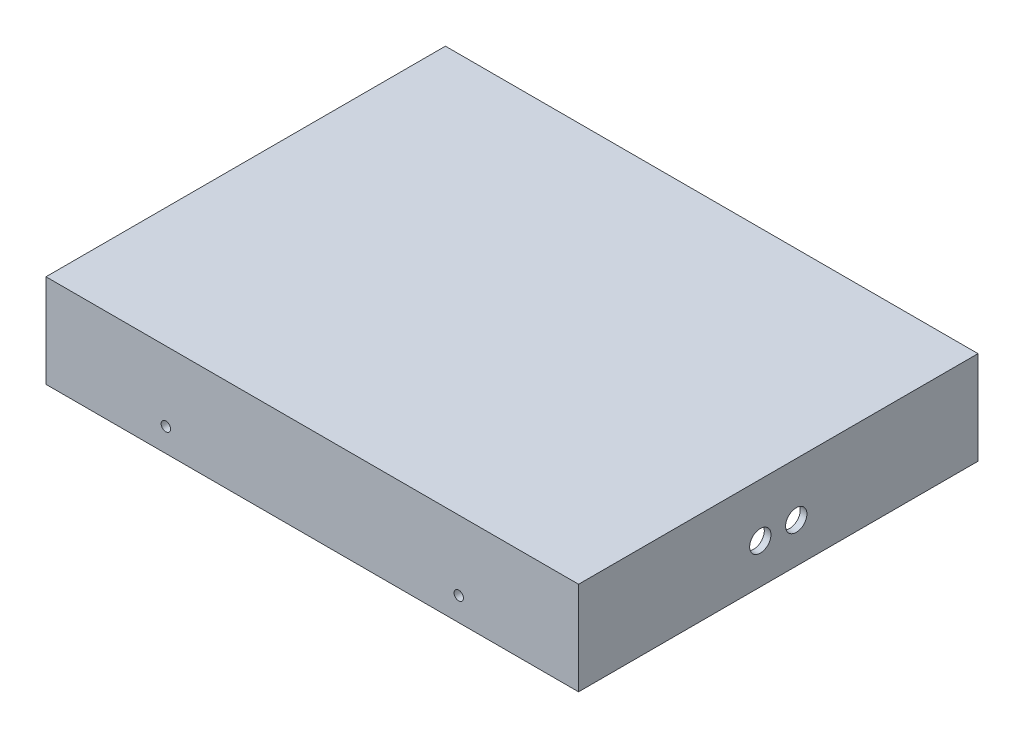
from build123d import *

# Parameters (mm, degrees)
SKETCH1_W           = 400
SKETCH1_H           = 300
BOSS_EXTRUDE1_DEPTH = 70
SKETCH2_W           = 390
SKETCH2_H           = 290
CUT_EXTRUDE1_DEPTH  = 60
FILLET2_R           = 10
SKETCH6_R           = 8
CUT_EXTRUDE3_DEPTH  = 10
SKETCH7_R           = 3.535
CUT_EXTRUDE4_DEPTH  = 459


with BuildPart() as part:
    # Sketch1 → Boss-Extrude1 (new body)
    with BuildSketch(Plane(origin=(0, 0, 0), x_dir=(1, 0, 0), z_dir=(0, 1, 0))):
        Rectangle(SKETCH1_W, SKETCH1_H)
    extrude(amount=BOSS_EXTRUDE1_DEPTH)

    # Sketch2 → Cut-Extrude1 (cut)
    with BuildSketch(Plane.XZ):
        Rectangle(SKETCH2_W, SKETCH2_H)
    extrude(amount=-CUT_EXTRUDE1_DEPTH, mode=Mode.SUBTRACT)

    # Fillet2
    fillet2_edges = [part.edges().sort_by_distance(p)[0] for p in [
        (195, 30, 145),
        (195, 30, -145),
        (-195, 30, -145),
        (-195, 30, 145),
    ]]
    fillet(fillet2_edges, radius=FILLET2_R)

    # Sketch6 → Cut-Extrude3 (cut)
    with BuildSketch(Plane(origin=(200, 0, 0), x_dir=(0, 0, -1), z_dir=(1, 0, 0))):
        with Locations((-13.5, 30)):
            Circle(SKETCH6_R)
        with Locations((13.5, 30)):
            Circle(SKETCH6_R)
    extrude(amount=-CUT_EXTRUDE3_DEPTH, mode=Mode.SUBTRACT)

    # Sketch7 → Cut-Extrude4 (cut)
    with BuildSketch(Plane.XY.offset(150)):
        with Locations((-110, 17.670088152)):
            Circle(SKETCH7_R)
        with Locations((110, 17.670088152)):
            Circle(SKETCH7_R)
    extrude(amount=-CUT_EXTRUDE4_DEPTH, mode=Mode.SUBTRACT)


solid = part.part
